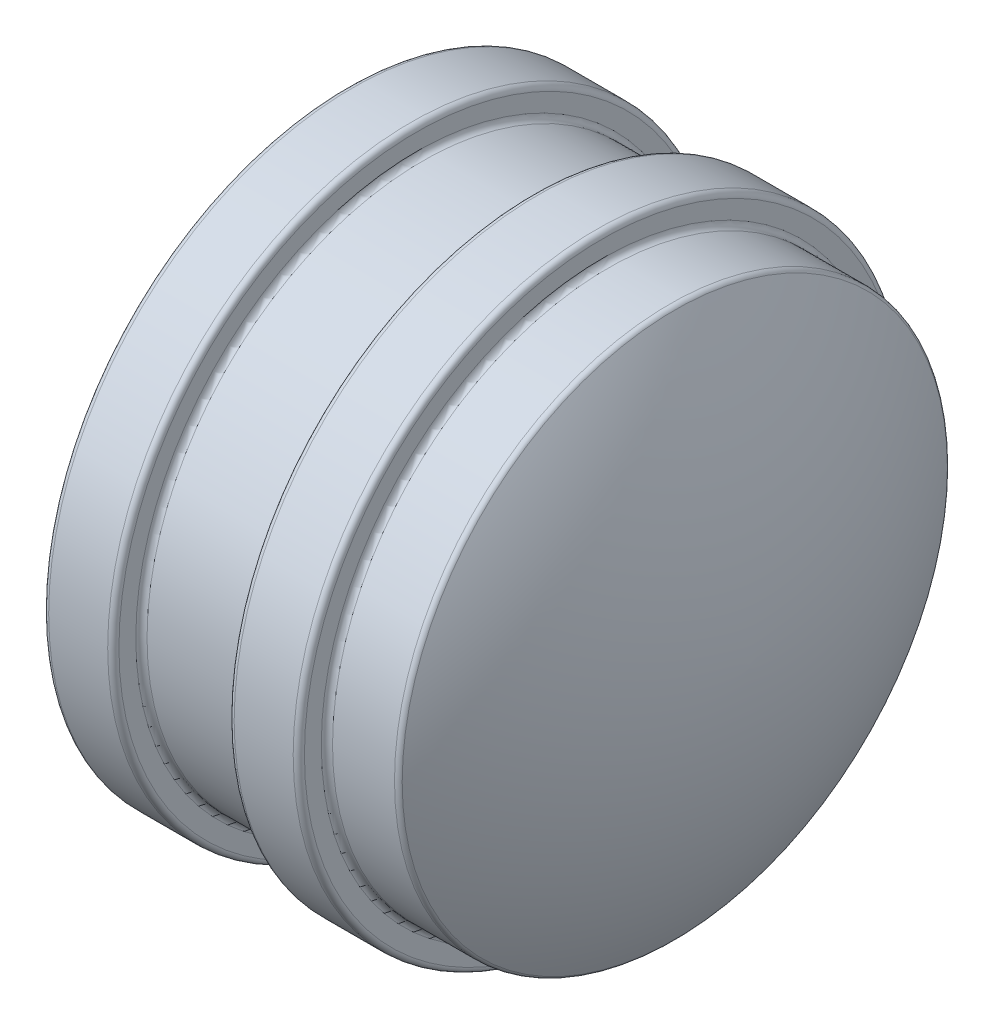
from build123d import *

# Parameters (mm, degrees)
FILLET1_R          = 0.254
SKETCH3_R          = 2.54
SKETCH3_R_2        = 2.286
CUT_EXTRUDE1_DEPTH = 6.35
FILLET2_R          = 1.27
FILLET3_R          = 0.254


with BuildPart() as part:
    # Sketch2 → Revolve1 (revolve)
    with BuildSketch(Plane.XY):
        with BuildLine():
            Line((0, 0), (18.1864, 0))
            ThreePointArc((18.1864, 0), (17.275816652, 6.444487241), (14.7574, 12.446))
            Line((14.7574, 12.446), (11.557, 12.446))
            Line((11.557, 12.446), (11.557, 13.716))
            Line((11.557, 13.716), (8.382, 13.716))
            Line((8.382, 13.716), (8.382, 12.446))
            Line((8.382, 12.446), (3.175, 12.446))
            Line((3.175, 12.446), (3.175, 13.716))
            Line((3.175, 13.716), (0, 13.716))
            Line((0, 13.716), (0, 0))
        make_face()
    revolve(axis=Axis((0, 0, 0), (1, 0, 0)))

    # Fillet1
    fillet1_edges = [part.edges().sort_by_distance(p)[0] for p in [
        (3.175, -12.446, 0),
        (3.175, -13.716, 0),
        (0, -13.716, 0),
        (14.7574, -12.446, 0),
        (11.557, -12.446, 0),
        (11.557, -13.716, 0),
        (8.382, -13.716, 0),
        (8.382, -12.446, 0),
    ]]
    fillet(fillet1_edges, radius=FILLET1_R)

    # Sketch3 → Cut-Extrude1 (cut)
    with BuildSketch(Plane.ZY):
        Circle(SKETCH3_R)
        with Locations((0, 7.112)):
            Circle(SKETCH3_R_2)
        with Locations((5.028943428, 5.028943428)):
            Circle(SKETCH3_R_2)
        with Locations((7.112, 0)):
            Circle(SKETCH3_R_2)
        with Locations((5.028943428, -5.028943428)):
            Circle(SKETCH3_R_2)
        with Locations((0, -7.112)):
            Circle(SKETCH3_R_2)
        with Locations((-5.028943428, -5.028943428)):
            Circle(SKETCH3_R_2)
        with Locations((-7.112, 0)):
            Circle(SKETCH3_R_2)
        with Locations((-5.028943428, 5.028943428)):
            Circle(SKETCH3_R_2)
    extrude(amount=-CUT_EXTRUDE1_DEPTH, mode=Mode.SUBTRACT)

    # Fillet2
    fillet2_edges = [part.edges().sort_by_distance(p)[0] for p in [
        (6.35, 0, -2.54),
        (6.35, 7.112, -2.286),
        (6.35, 5.028943428, 2.742943428),
        (6.35, 0, 4.826),
        (6.35, -5.028943428, 2.742943428),
        (6.35, -7.112, -2.286),
        (6.35, -5.028943428, -7.314943428),
        (6.35, 0, -9.398),
        (6.35, 5.028943428, -7.314943428),
    ]]
    fillet(fillet2_edges, radius=FILLET2_R)

    # Fillet3
    fillet3_edges = [part.edges().sort_by_distance(p)[0] for p in [
        (0, 0, -2.54),
        (0, 7.112, -2.286),
        (0, 5.028943428, 2.742943428),
        (0, 0, 4.826),
        (0, -5.028943428, 2.742943428),
        (0, -7.112, -2.286),
        (0, -5.028943428, -7.314943428),
        (0, 0, -9.398),
        (0, 5.028943428, -7.314943428),
    ]]
    fillet(fillet3_edges, radius=FILLET3_R)


solid = part.part
